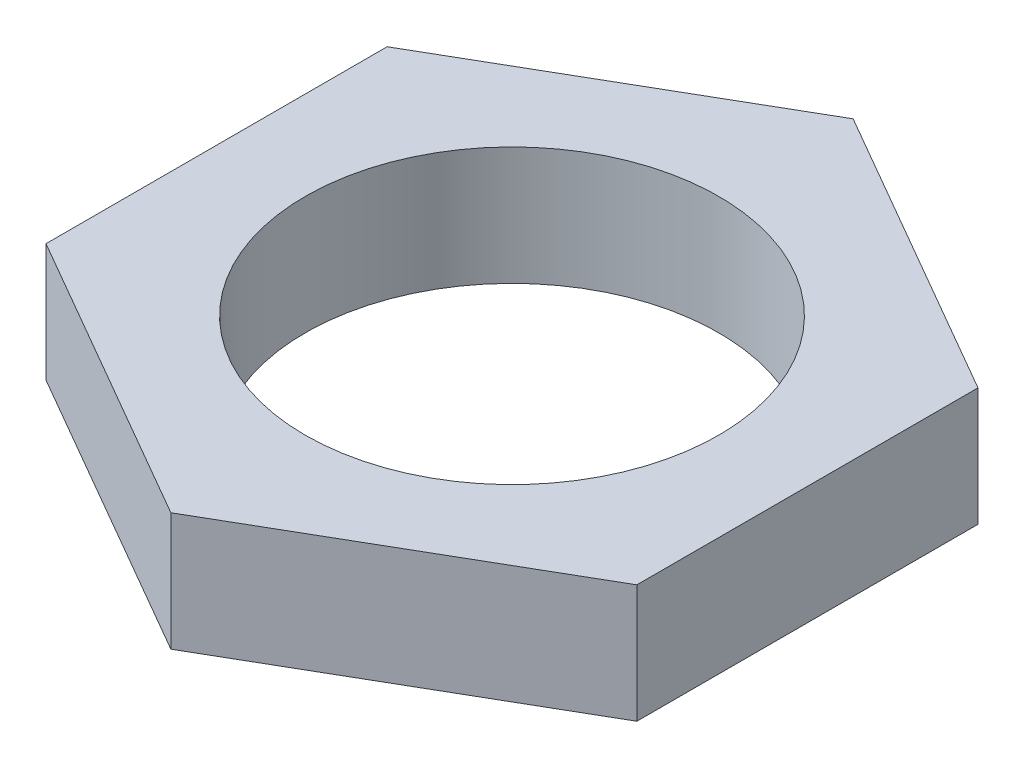
from build123d import *

# Parameters (mm, degrees)
SKETCH1_R           = 16.66875
BOSS_EXTRUDE1_DEPTH = 4.7625


with BuildPart() as part:
    # Sketch1 → Boss-Extrude1 (new body, symmetric)
    with BuildSketch(Plane(origin=(0, 0, 0), x_dir=(1, 0, 0), z_dir=(0, 1, 0))):
        Polygon((0, 27.49630657), (-23.8125, 13.748153285), (-23.8125, -13.748153285), (0, -27.49630657), (23.8125, -13.748153285), (23.8125, 13.748153285), align=None)
        Circle(SKETCH1_R, mode=Mode.SUBTRACT)
    extrude(amount=BOSS_EXTRUDE1_DEPTH, both=True)


solid = part.part
